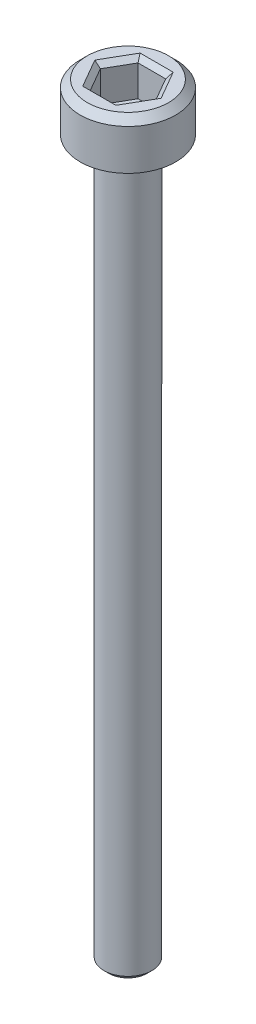
from build123d import *

# Parameters (mm, degrees)
SKETCH1_R           = 2
BOSS_EXTRUDE1_DEPTH = 2
CHAMFER1_SIZE       = 0.3
CUT_EXTRUDE1_DEPTH  = 1.5
CHAMFER2_SIZE       = 0.2
SKETCH3_R           = 1
BOSS_EXTRUDE2_DEPTH = 30
CHAMFER3_SIZE       = 0.2


with BuildPart() as part:
    # Sketch1 → Boss-Extrude1 (new body)
    with BuildSketch(Plane(origin=(0, 0, 0), x_dir=(1, 0, 0), z_dir=(0, 1, 0))):
        with Locations(Location((0, 0, 0), (0, 0, 270))):  # turned: the seam where the file's is
            Circle(SKETCH1_R)
    extrude(amount=BOSS_EXTRUDE1_DEPTH)

    # Chamfer1
    chamfer1_edges = [part.edges().sort_by_distance(p)[0] for p in [
        (0, 2, -2),
    ]]
    chamfer(chamfer1_edges, length=CHAMFER1_SIZE)

    # Sketch2 → Cut-Extrude1 (cut)
    with BuildSketch(Plane(origin=(0, 2, 0), x_dir=(1, 0, 0), z_dir=(0, 1, 0))):
        Polygon((1.154700538, 0), (0.577350269, 1), (-0.577350269, 1), (-1.154700538, 0), (-0.577350269, -1), (0.577350269, -1), align=None)
    extrude(amount=-CUT_EXTRUDE1_DEPTH, mode=Mode.SUBTRACT)

    # Chamfer2
    chamfer2_edges = [part.edges().sort_by_distance(p)[0] for p in [
        (0.866025404, 2, 0.5),
        (0.866025404, 2, -0.5),
        (0, 2, -1),
        (-0.866025404, 2, -0.5),
        (-0.866025404, 2, 0.5),
        (0, 2, 1),
    ]]
    chamfer(chamfer2_edges, length=CHAMFER2_SIZE)

    # Sketch3 → Boss-Extrude2 (add)
    with BuildSketch(Plane.XZ):
        with Locations(Location((0, 0, 0), (0, 0, 90))):  # turned: the seam where the file's is
            Circle(SKETCH3_R)
    extrude(amount=BOSS_EXTRUDE2_DEPTH)

    # Chamfer3
    chamfer3_edges = [part.edges().sort_by_distance(p)[0] for p in [
        (0, -30, -1),
    ]]
    chamfer(chamfer3_edges, length=CHAMFER3_SIZE)


solid = part.part
